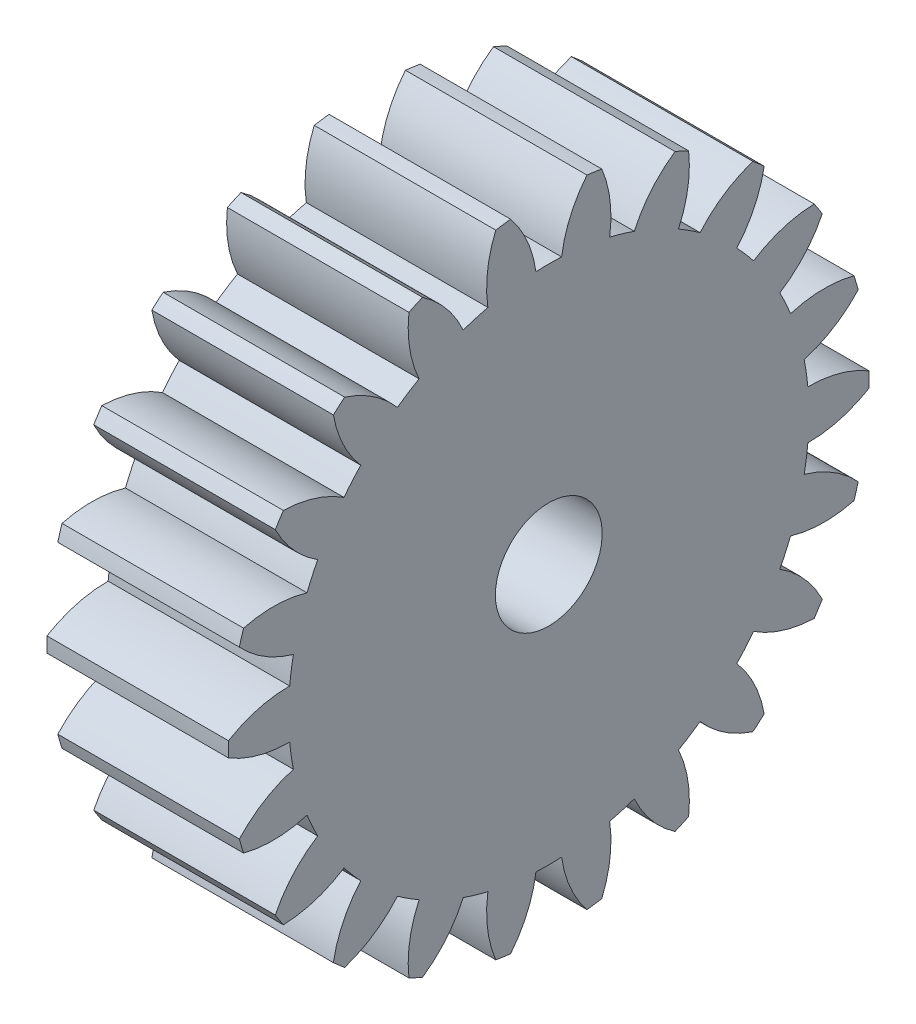
from build123d import *

# Parameters (mm, degrees)
BASPROSKE_W     = 1.7
BASPROSKE_H     = 3
TOOTHCUT_DEPTH  = 5.570557953
TEETHCUTS_COUNT = 22
TEETHCUTS_ANGLE = 343.636363636
BORSKE_R        = 0.5
BORE_DEPTH      = 50.0000508


with BuildPart() as part:
    # BasProSke → Base-Revolve (revolve)
    with BuildSketch(Plane(origin=(0, 0, 0), x_dir=(1, 0, 0), z_dir=(0, 1, 0)), mode=Mode.PRIVATE) as base_revolve_sk:
        with Locations((0.85, 1.5)):
            Rectangle(BASPROSKE_W, BASPROSKE_H)
    revolve(base_revolve_sk.sketch.rotate(Axis((-10, 0, 0), (1, 0, 0)), 180), axis=Axis((-10, 0, 0), (1, 0, 0)))

    # TooCutSke → ToothCut (cut, through all)
    with BuildSketch(Plane(origin=(0, 0, 0), x_dir=(0, 0, -1), z_dir=(1, 0, 0))):
        with BuildLine():
            ThreePointArc((0.120318822, 2.433527405), (0, 2.4365), (-0.120318822, 2.433527405))
            ThreePointArc((-0.120318822, 2.433527405), (-0.207576962, 2.736243526), (-0.37706112, 3.001811132))
            ThreePointArc((-0.37706112, 3.001811132), (0, 3.0254), (0.37706112, 3.001811132))
            ThreePointArc((0.37706112, 3.001811132), (0.207576962, 2.736243526), (0.120318822, 2.433527405))
        make_face()
    toothcut = extrude(amount=TOOTHCUT_DEPTH, mode=Mode.SUBTRACT)

    # TeethCuts: ToothCut ×22 about axis
    teethcuts_axis = Axis((-10, 0, 0), (1, 0, 0))
    for i in range(1, TEETHCUTS_COUNT):
        add(toothcut.rotate(teethcuts_axis, i * TEETHCUTS_ANGLE / (TEETHCUTS_COUNT - 1)), mode=Mode.SUBTRACT)

    # BorSke → Bore (cut, symmetric)
    with BuildSketch(Plane(origin=(0, 0, 0), x_dir=(0, 0, -1), z_dir=(1, 0, 0))):
        with Locations(Location((0, 0, 0), (0, 0, 180))):
            Circle(BORSKE_R)
    extrude(amount=BORE_DEPTH, both=True, mode=Mode.SUBTRACT)


solid = part.part
